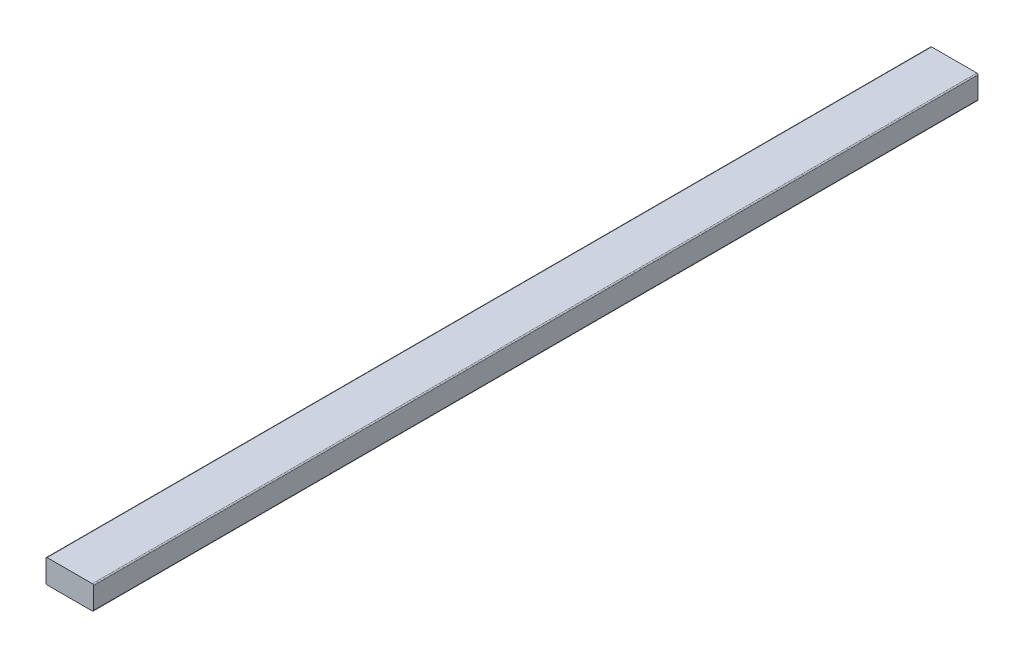
from build123d import *

# Parameters (mm, degrees)
SKETCH1_W           = 40
SKETCH1_H           = 20
BOSS_EXTRUDE1_DEPTH = 745
FILLET1_R           = 1


with BuildPart() as part:
    # Sketch1 → Boss-Extrude1 (new body)
    with BuildSketch(Plane.XY):
        Rectangle(SKETCH1_W, SKETCH1_H)
    extrude(amount=BOSS_EXTRUDE1_DEPTH)

    # Fillet1
    fillet1_edges = [part.edges().sort_by_distance(p)[0] for p in [
        (20, -10, 372.5),
        (-20, -10, 372.5),
        (-20, 10, 372.5),
        (20, 10, 372.5),
    ]]
    fillet(fillet1_edges, radius=FILLET1_R)


solid = part.part
